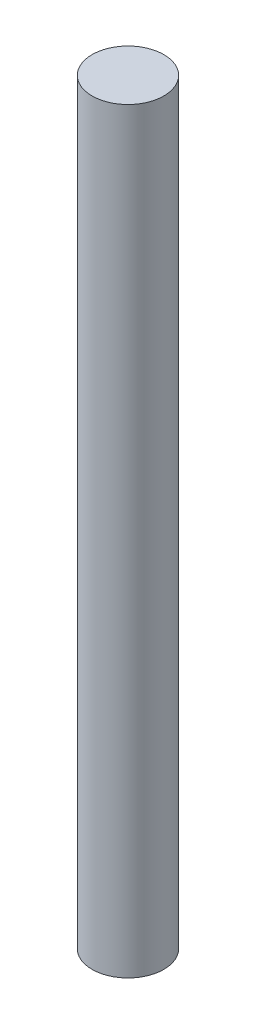
from build123d import *

# Parameters (mm, degrees)
SKETCH1_R           = 3.3655
BOSS_EXTRUDE1_DEPTH = 71


with BuildPart() as part:
    # Sketch1 → Boss-Extrude1 (new body)
    with BuildSketch(Plane(origin=(0, 0, 0), x_dir=(1, 0, 0), z_dir=(0, 1, 0))):
        Circle(SKETCH1_R)
    extrude(amount=BOSS_EXTRUDE1_DEPTH)


solid = part.part
